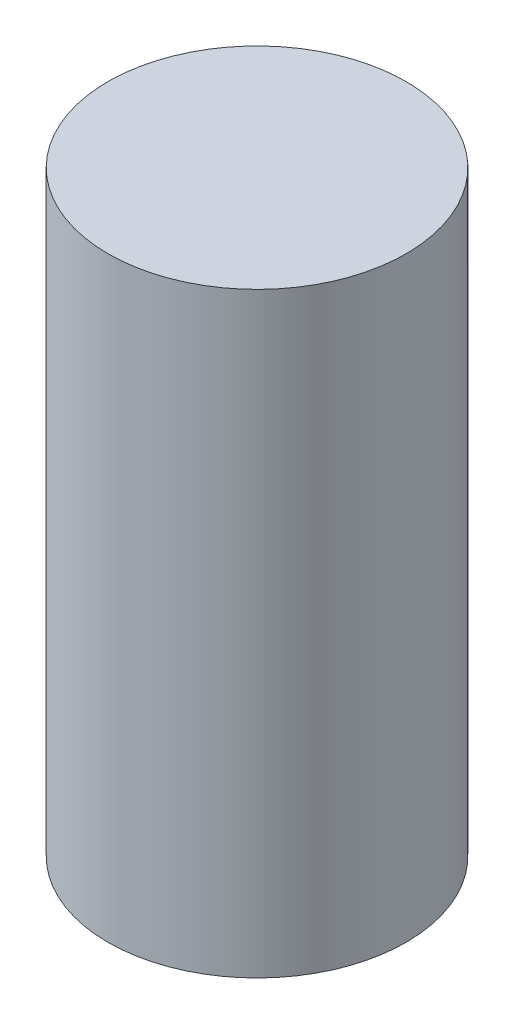
from build123d import *

# Parameters (mm, degrees)
SKIZZE1_R                       = 12.5
AUFSATZ_LINEAR_AUSTRAGEN1_DEPTH = 50


with BuildPart() as part:
    # Skizze1 → Aufsatz-Linear austragen1 (new body)
    with BuildSketch(Plane(origin=(0, 0, 0), x_dir=(1, 0, 0), z_dir=(0, 1, 0))):
        Circle(SKIZZE1_R)
    extrude(amount=AUFSATZ_LINEAR_AUSTRAGEN1_DEPTH)


solid = part.part
